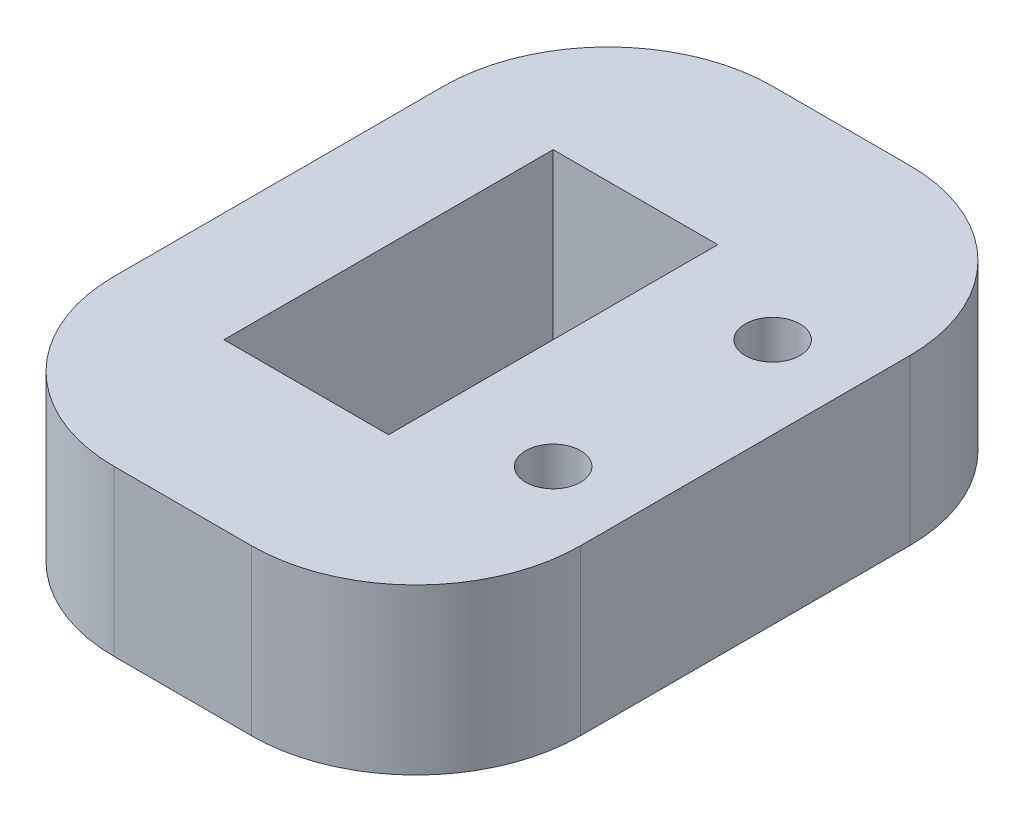
from build123d import *

# Parameters (mm, degrees)
SKETCH1_W           = 8.5
SKETCH1_H           = 12
SKETCH1_R           = 0.5
SKETCH1_W_2         = 3
SKETCH1_H_2         = 6
BOSS_EXTRUDE1_DEPTH = 1.5
FILLET1_R           = 3


with BuildPart() as part:
    # Sketch1 → Boss-Extrude1 (new body, symmetric)
    with BuildSketch(Plane(origin=(0, 0, 0), x_dir=(1, 0, 0), z_dir=(0, 1, 0))):
        Rectangle(SKETCH1_W, SKETCH1_H)
        with Locations((2.75, 2)):
            Circle(SKETCH1_R, mode=Mode.SUBTRACT)
        with Locations((2.75, -2)):
            Circle(SKETCH1_R, mode=Mode.SUBTRACT)
        with Locations((-0.75, 0)):
            Rectangle(SKETCH1_W_2, SKETCH1_H_2, mode=Mode.SUBTRACT)
    extrude(amount=BOSS_EXTRUDE1_DEPTH, both=True)

    # Fillet1
    fillet1_edges = [part.edges().sort_by_distance(p)[0] for p in [
        (-4.25, 0, -6),
        (4.25, 0, -6),
        (4.25, 0, 6),
        (-4.25, 0, 6),
    ]]
    fillet(fillet1_edges, radius=FILLET1_R)


solid = part.part
